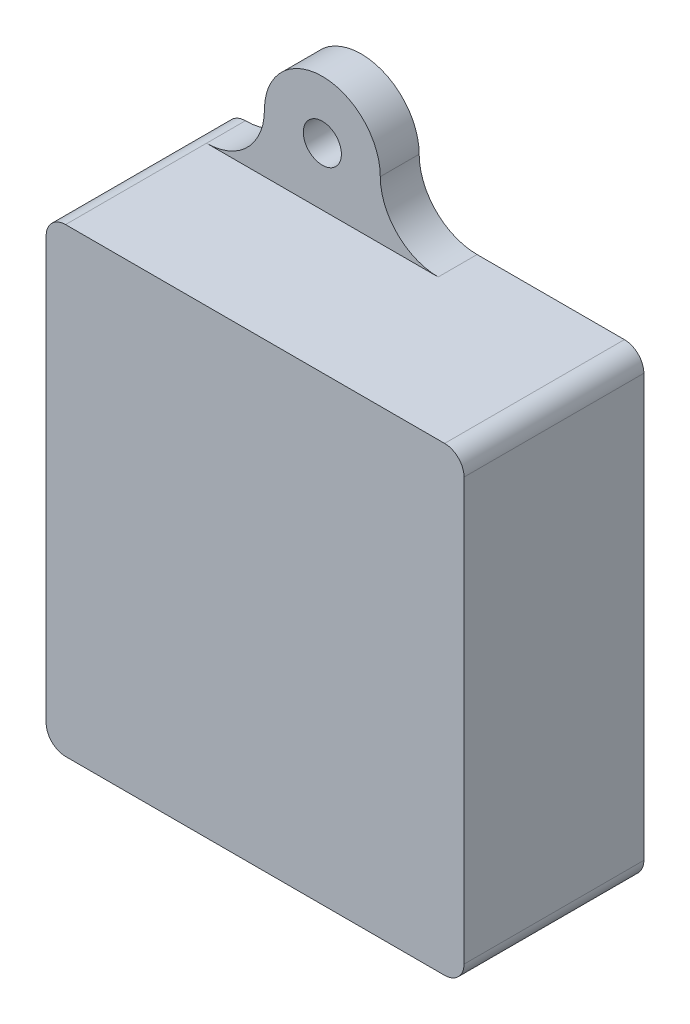
from build123d import *

# Parameters (mm, degrees)
BOSS_EXTRUDE1_DEPTH = 23.495
SHELL1_T            = -3.429
FILLET1_R           = 2.54
SKETCH2_R           = 7.5692
SKETCH2_R_2         = 2.4892
BOSS_EXTRUDE2_DEPTH = 5.08
CUT_EXTRUDE1_REACH  = 56.61
SKETCH3_W           = 3.81
SKETCH3_H           = 40.3352
FILLET2_R           = 1.27


with BuildPart() as part:
    # Sketch1 → Boss-Extrude1 (new body)
    with BuildSketch(Plane.XY):
        with BuildLine():
            Line((2.54, 0), (52.07, 0))
            ThreePointArc((52.07, 0), (53.866051224, 0.743948776), (54.61, 2.54))
            Line((54.61, 2.54), (54.61, 57.658))
            ThreePointArc((54.61, 57.658), (53.866051224, 59.454051224), (52.07, 60.198))
            Line((52.07, 60.198), (2.54, 60.198))
            ThreePointArc((2.54, 60.198), (0.743948776, 59.454051224), (0, 57.658))
            Line((0, 57.658), (0, 2.54))
            ThreePointArc((0, 2.54), (0.743948776, 0.743948776), (2.54, 0))
        make_face()
    extrude(amount=BOSS_EXTRUDE1_DEPTH)

    # Shell1
    shell1_openings = [part.faces().sort_by_distance(p)[0] for p in [
        (27.305, 30.099, 0),
    ]]
    offset(amount=SHELL1_T, openings=shell1_openings, kind=Kind.INTERSECTION)

    # Fillet1
    fillet1_edges = [part.edges().sort_by_distance(p)[0] for p in [
        (3.429, 3.429, 10.033),
        (51.181, 3.429, 10.033),
        (51.181, 56.769, 10.033),
        (3.429, 56.769, 10.033),
    ]]
    fillet(fillet1_edges, radius=FILLET1_R)

    # Sketch2 → Boss-Extrude2 (add)
    with BuildSketch(Plane(origin=(0, 0, 0), x_dir=(-1, 0, 0), z_dir=(0, 0, -1))):
        with BuildLine():
            ThreePointArc((-17.6784, 60.198), (-23.030632648, 62.414967352), (-25.2476, 67.7672))
            ThreePointArc((-25.2476, 67.7672), (-27.464567352, 62.414967352), (-32.8168, 60.198))
            Line((-32.8168, 60.198), (-17.6784, 60.198))
        make_face()
        with Locations((-17.6784, 67.7672)):
            Circle(SKETCH2_R)
        with Locations((-17.6784, 67.7672)):
            Circle(SKETCH2_R_2, mode=Mode.SUBTRACT)
        with BuildLine():
            ThreePointArc((-2.54, 60.198), (-7.892232648, 62.414967352), (-10.1092, 67.7672))
            ThreePointArc((-10.1092, 67.7672), (-12.326167352, 62.414967352), (-17.6784, 60.198))
            Line((-17.6784, 60.198), (-2.54, 60.198))
        make_face()
        with Locations((-17.6784, -7.5692)):
            Circle(SKETCH2_R)
        with Locations((-17.6784, -7.5692)):
            Circle(SKETCH2_R_2, mode=Mode.SUBTRACT)
        with BuildLine():
            ThreePointArc((-32.8168, 0), (-27.464567352, -2.216967352), (-25.2476, -7.5692))
            ThreePointArc((-25.2476, -7.5692), (-23.03063266, -2.216967364), (-17.678400033, 0))
            Line((-17.678400033, 0), (-32.8168, 0))
        make_face()
        with BuildLine():
            ThreePointArc((-17.678400033, 0), (-12.326167364, -2.21696734), (-10.1092, -7.5692))
            ThreePointArc((-10.1092, -7.5692), (-7.892232648, -2.216967352), (-2.54, 0))
            Line((-2.54, 0), (-17.678400033, 0))
        make_face()
    extrude(amount=-BOSS_EXTRUDE2_DEPTH)

    # Sketch3 → Cut-Extrude1 (cut, up to next)
    with BuildSketch(Plane.ZY, mode=Mode.PRIVATE) as cut_extrude1_sk1:
        with Locations((1.905, 26.1366)):
            Rectangle(SKETCH3_W, SKETCH3_H)
    cut_extrude1_tool1 = extrude(cut_extrude1_sk1.sketch, amount=-CUT_EXTRUDE1_REACH, mode=Mode.PRIVATE) & part.part
    add(cut_extrude1_tool1.solids().sort_by_distance((0, 26.1366, 1.905))[0], mode=Mode.SUBTRACT)

    # Fillet2
    fillet2_edges = [part.edges().sort_by_distance(p)[0] for p in [
        (3.429, 46.3042, 1.905),
        (3.429, 5.969, 1.905),
        (0, 5.969, 1.905),
        (0, 46.3042, 1.905),
    ]]
    fillet(fillet2_edges, radius=FILLET2_R)


solid = part.part
